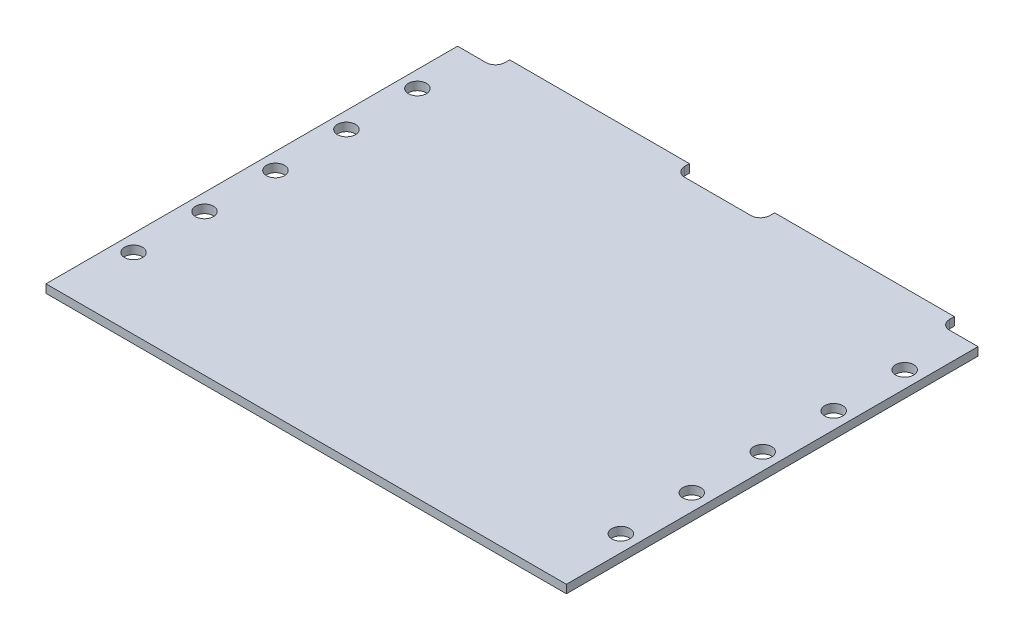
from build123d import *

# Parameters (mm, degrees)
FR4_DEPTH          = 1.7526
SKETCH7_R          = 1.905
CUT_EXTRUDE1_DEPTH = 2.7526


with BuildPart() as part:
    # Sketch1 → FR4 (new body)
    with BuildSketch(Plane(origin=(0, 0, 0), x_dir=(1, 0, 0), z_dir=(0, 1, 0))):
        with BuildLine():
            Line((0, 0), (110, 0))
            Line((110, 0), (110, 87))
            Line((110, 87), (104, 87))
            ThreePointArc((104, 87), (102.585786438, 87.585786438), (102, 89))
            Line((102, 89), (102, 90))
            Line((102, 90), (64, 90))
            Line((64, 90), (64, 89))
            ThreePointArc((64, 89), (63.414213562, 87.585786438), (62, 87))
            Line((62, 87), (48, 87))
            ThreePointArc((48, 87), (46.585786438, 87.585786438), (46, 89))
            Line((46, 89), (46, 90))
            Line((46, 90), (8, 90))
            Line((8, 90), (8, 89))
            ThreePointArc((8, 89), (7.414213562, 87.585786438), (6, 87))
            Line((6, 87), (0, 87))
            Line((0, 87), (0, 0))
        make_face()
    extrude(amount=FR4_DEPTH)

    # Sketch7 → Cut-Extrude1 (cut, through all)
    with BuildSketch(Plane(origin=(0, 1.7526, 0), x_dir=(1, 0, 0), z_dir=(0, 1, 0))):
        with Locations((3.5, 15)):
            Circle(SKETCH7_R)
        with Locations((106.5, 15)):
            Circle(SKETCH7_R)
        with Locations((106.5, 30)):
            Circle(SKETCH7_R)
        with Locations((106.5, 45)):
            Circle(SKETCH7_R)
        with Locations((106.5, 60)):
            Circle(SKETCH7_R)
        with Locations((106.5, 75)):
            Circle(SKETCH7_R)
        with Locations((3.5, 30)):
            Circle(SKETCH7_R)
        with Locations((3.5, 45)):
            Circle(SKETCH7_R)
        with Locations((3.5, 60)):
            Circle(SKETCH7_R)
        with Locations((3.5, 75)):
            Circle(SKETCH7_R)
    extrude(amount=-CUT_EXTRUDE1_DEPTH, mode=Mode.SUBTRACT)


solid = part.part
